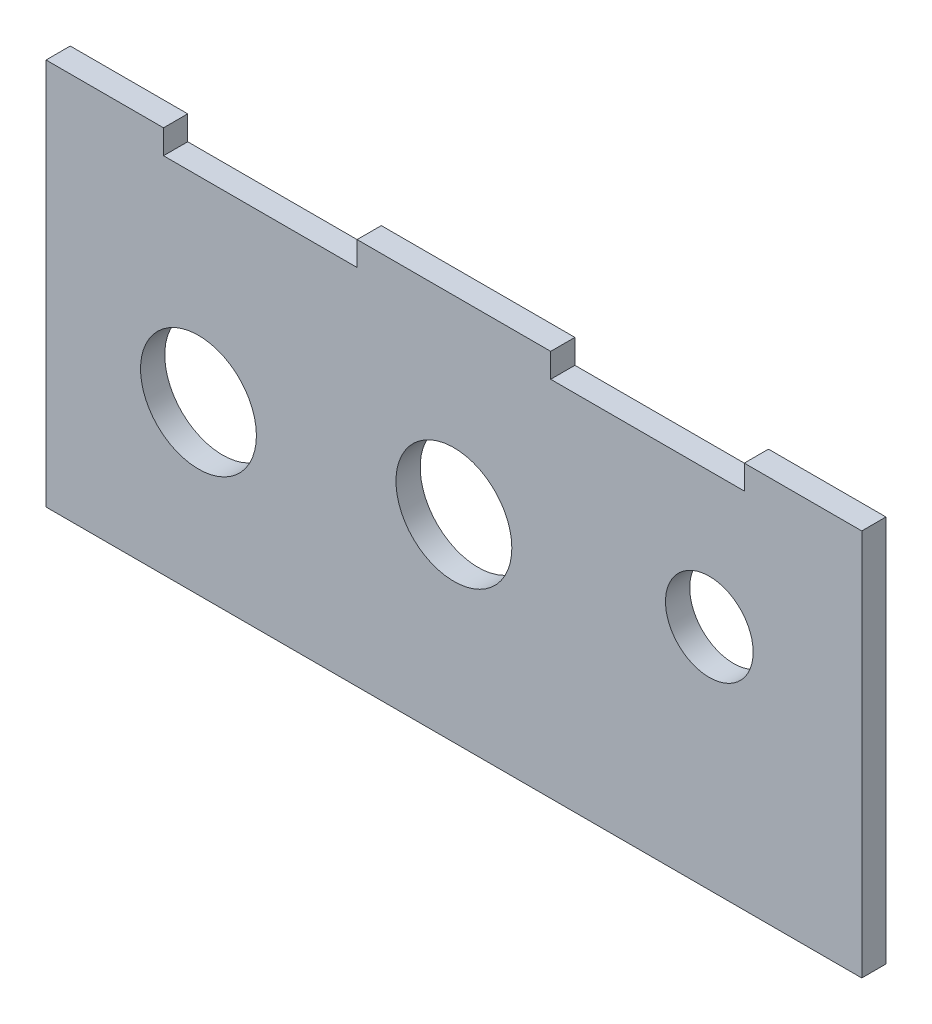
from build123d import *

# Parameters (mm, degrees)
SKETCH1_R           = 7.6
SKETCH1_R_2         = 5.75
BOSS_EXTRUDE1_DEPTH = 3.175


with BuildPart() as part:
    # Sketch1 → Boss-Extrude1 (new body)
    with BuildSketch(Plane.XY):
        Polygon((0, 50.8), (0, 0), (107.025740158, 0), (107.025740158, 50.8), (91.612870079, 50.8), (91.612870079, 47.625), (66.212870079, 47.625), (66.212870079, 50.8), (40.812870079, 50.8), (40.812870079, 47.625), (15.412870079, 47.625), (15.412870079, 50.8), align=None)
        with Locations((20, 21.9125)):
            Circle(SKETCH1_R, mode=Mode.SUBTRACT)
        with Locations((53.512864121, 25.9063)):
            Circle(SKETCH1_R, mode=Mode.SUBTRACT)
        with Locations((87.025740158, 29.9)):
            Circle(SKETCH1_R_2, mode=Mode.SUBTRACT)
    extrude(amount=BOSS_EXTRUDE1_DEPTH)


solid = part.part
